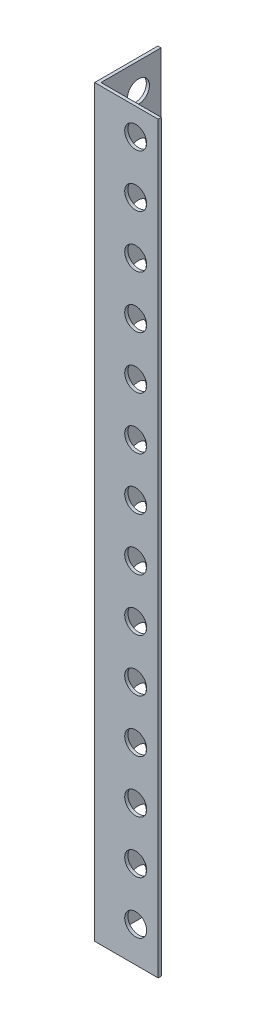
from build123d import *

# Parameters (mm, degrees)
BOSS_EXTRUDE2_DEPTH = 363.031
SKETCH2_R           = 5.35
CUT_EXTRUDE1_DEPTH  = 32.0261
SKETCH3_R           = 5.35
CUT_EXTRUDE2_DEPTH  = 31.861
LPATTERN2_COUNT     = 15
LPATTERN2_PITCH     = 25.6


with BuildPart() as part:
    # Sketch1 → Boss-Extrude2 (new body)
    with BuildSketch(Plane(origin=(0, 0, 0), x_dir=(1, 0, 0), z_dir=(0, 1, 0))):
        Polygon((0, 0), (31.0261, 0), (31.0261, 1.54), (1.54, 1.54), (1.54, 30.861), (0, 30.861), align=None)
    extrude(amount=BOSS_EXTRUDE2_DEPTH)

    # Sketch2 → Cut-Extrude1 (cut, through all)
    with BuildSketch(Plane.ZY):
        with Locations((-19.861, 350.031)):
            Circle(SKETCH2_R)
    cut_extrude1 = extrude(amount=-CUT_EXTRUDE1_DEPTH, mode=Mode.SUBTRACT)

    # Sketch3 → Cut-Extrude2 (cut, through all)
    with BuildSketch(Plane.XY):
        with Locations((20.0261, 350.031)):
            Circle(SKETCH3_R)
    cut_extrude2 = extrude(amount=-CUT_EXTRUDE2_DEPTH, mode=Mode.SUBTRACT)

    # LPattern2: Cut-Extrude1, Cut-Extrude2 ×15
    with Locations(*[(0, -i * LPATTERN2_PITCH, 0) for i in range(1, LPATTERN2_COUNT)]):
        add(cut_extrude1, mode=Mode.SUBTRACT)
        add(cut_extrude2, mode=Mode.SUBTRACT)


solid = part.part
